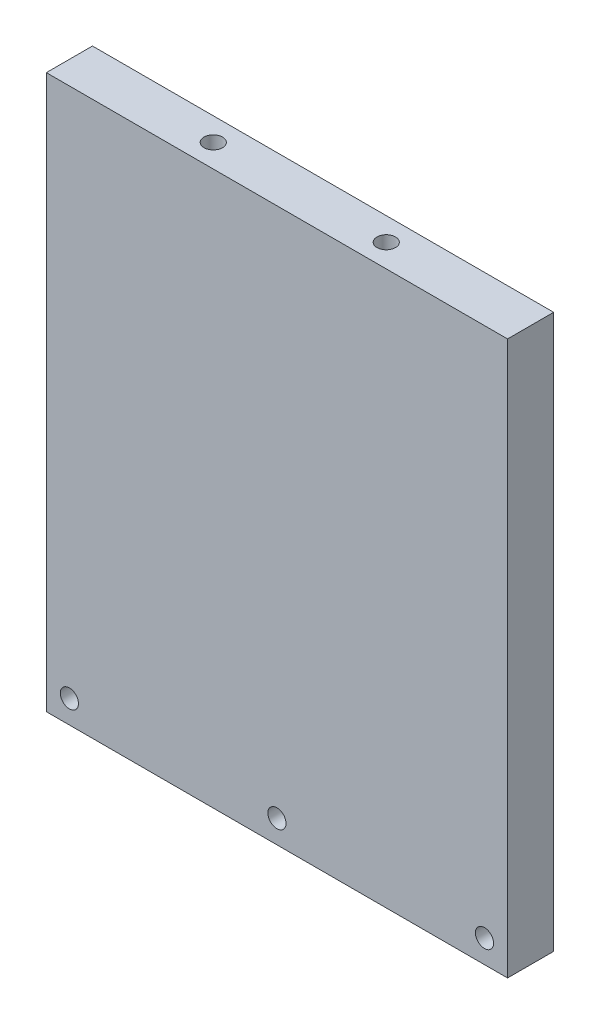
from build123d import *

# Parameters (mm, degrees)
SKETCH1_W                         = 254
SKETCH1_H                         = 304.8
BOSS_EXTRUDE1_DEPTH               = 25.4
F_10_0_10_DIAMETER_HOLE1_D        = 10
TAP_DRILL_FOR_M12X1_75_TAP1_D     = 10.2
TAP_DRILL_FOR_M12X1_75_TAP1_DEPTH = 30
TAP_DRILL_FOR_M12X1_75_TAP1_TIP   = 3.064389157


with BuildPart() as part:
    # Sketch1 → Boss-Extrude1 (new body)
    with BuildSketch(Plane.XY):
        Rectangle(SKETCH1_W, SKETCH1_H)
    extrude(amount=BOSS_EXTRUDE1_DEPTH)

    # Ø10.0 (10) Diameter Hole1 (through all)
    with Locations(Plane.XY.offset(25.4)):
        with Locations((-114.3, -139.7), (0, -139.7), (114.3, -139.7)):
            Hole(F_10_0_10_DIAMETER_HOLE1_D / 2)

    # Tap Drill for M12x1.75 Tap1
    with Locations(Plane(origin=(0, 152.4, 0), x_dir=(1, 0, 0), z_dir=(0, 1, 0))):
        with Locations((-47.754, -12.7), (47.498, -12.7)):
            Hole(TAP_DRILL_FOR_M12X1_75_TAP1_D / 2, depth=TAP_DRILL_FOR_M12X1_75_TAP1_DEPTH)
            with Locations((0, 0, -(TAP_DRILL_FOR_M12X1_75_TAP1_DEPTH + TAP_DRILL_FOR_M12X1_75_TAP1_TIP / 2))):  # 118° drill point
                Cone(0, TAP_DRILL_FOR_M12X1_75_TAP1_D / 2, TAP_DRILL_FOR_M12X1_75_TAP1_TIP, mode=Mode.SUBTRACT)


solid = part.part
